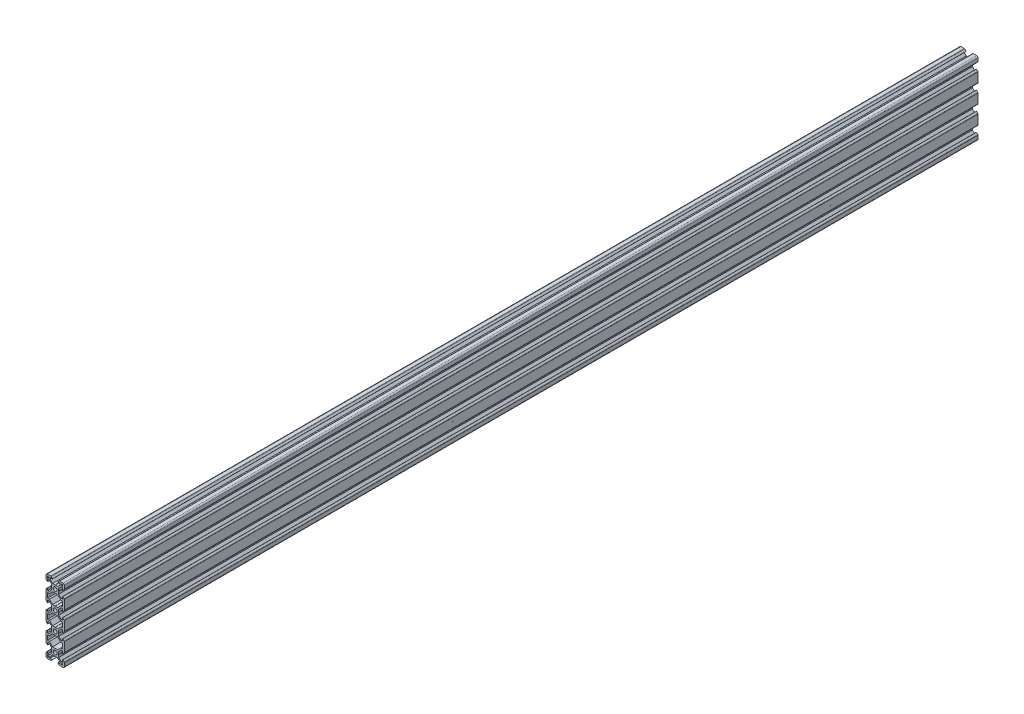
from build123d import *

# Parameters (mm, degrees)
SKETCH3_R           = 2.1
BOSS_EXTRUDE1_DEPTH = 1000


with BuildPart() as part:
    # Sketch3 → Boss-Extrude1 (new body)
    with BuildSketch(Plane.XY):
        with BuildLine():
            Line((-0.1, 3.9), (0, 3.8))
            Line((0, 3.8), (0.1, 3.9))
            Line((0.1, 3.9), (2.840365134, 3.9))
            Line((2.840365134, 3.9), (5.5, 6.558825842))
            Line((5.5, 6.558825842), (5.5, 8.197505675))
            Line((5.5, 8.197505675), (2.89, 8.197505675))
            Line((2.89, 8.197505675), (2.89, 8.307505675))
            Line((2.89, 8.307505675), (4.348614357, 9.766120032))
            ThreePointArc((4.348614357, 9.766120032), (4.604908803, 9.937370505), (4.907228714, 9.997505675))
            Line((4.907228714, 9.997505675), (8.5, 9.997505675))
            ThreePointArc((8.5, 9.997505675), (9.560660172, 9.558165846), (10, 8.497505675))
            Line((10, 8.497505675), (10, 4.904734389))
            ThreePointArc((10, 4.904734389), (9.939864831, 4.602414477), (9.768614357, 4.346120032))
            Line((9.768614357, 4.346120032), (8.31, 2.887505675))
            Line((8.31, 2.887505675), (8.2, 2.887505675))
            Line((8.2, 2.887505675), (8.2, 5.497505675))
            Line((8.2, 5.497505675), (6.56, 5.497505675))
            Line((6.56, 5.497505675), (3.9, 2.83831481))
            Line((3.9, 2.83831481), (3.9, 0.1))
            Line((3.9, 0.1), (3.8, 0))
            Line((3.8, 0), (3.9, -0.1))
            Line((3.9, -0.1), (3.9, -2.84))
            Line((3.9, -2.84), (6.56, -5.5))
            Line((6.56, -5.5), (8.21, -5.5))
            Line((8.21, -5.5), (8.21, -2.89))
            Line((8.21, -2.89), (8.31, -2.89))
            Line((8.31, -2.89), (9.765685425, -4.345685425))
            ThreePointArc((9.765685425, -4.345685425), (9.939103626, -4.605224104), (10, -4.91137085))
            Line((10, -4.91137085), (10, -15.08862915))
            ThreePointArc((10, -15.08862915), (9.939103626, -15.394775896), (9.765685425, -15.654314575))
            Line((9.765685425, -15.654314575), (8.31, -17.11))
            Line((8.31, -17.11), (8.21, -17.11))
            Line((8.21, -17.11), (8.21, -14.5))
            Line((8.21, -14.5), (6.56, -14.5))
            Line((6.56, -14.5), (3.9, -17.16))
            Line((3.9, -17.16), (3.9, -19.9))
            Line((3.9, -19.9), (3.8, -20))
            Line((3.8, -20), (3.9, -20.1))
            Line((3.9, -20.1), (3.9, -22.838679656))
            Line((3.9, -22.838679656), (6.56, -25.498679656))
            Line((6.56, -25.498679656), (8.21, -25.498679656))
            Line((8.21, -25.498679656), (8.21, -22.888679656))
            Line((8.21, -22.888679656), (8.31, -22.888679656))
            Line((8.31, -22.888679656), (9.765685425, -24.344365081))
            ThreePointArc((9.765685425, -24.344365081), (9.939103626, -24.60390376), (10, -24.910050506))
            Line((10, -24.910050506), (10, -35.109949494))
            ThreePointArc((10, -35.109949494), (9.939103626, -35.41609624), (9.765685425, -35.675634919))
            Line((9.765685425, -35.675634919), (8.31, -37.131320344))
            Line((8.31, -37.131320344), (8.21, -37.131320344))
            Line((8.21, -37.131320344), (8.21, -34.521320344))
            Line((8.21, -34.521320344), (6.56, -34.521320344))
            Line((6.56, -34.521320344), (3.9, -37.181320344))
            Line((3.9, -37.181320344), (3.9, -39.92))
            Line((3.9, -39.92), (3.8, -40.02))
            Line((3.8, -40.02), (3.9, -40.12))
            Line((3.9, -40.12), (3.9, -42.86))
            Line((3.9, -42.86), (6.56, -45.52))
            Line((6.56, -45.52), (8.21, -45.52))
            Line((8.21, -45.52), (8.21, -42.91))
            Line((8.21, -42.91), (8.31, -42.91))
            Line((8.31, -42.91), (9.765685425, -44.365685425))
            ThreePointArc((9.765685425, -44.365685425), (9.939103626, -44.625224104), (10, -44.93137085))
            Line((10, -44.93137085), (10, -55.10862915))
            ThreePointArc((10, -55.10862915), (9.939103626, -55.414775896), (9.765685425, -55.674314575))
            Line((9.765685425, -55.674314575), (8.31, -57.13))
            Line((8.31, -57.13), (8.21, -57.13))
            Line((8.21, -57.13), (8.21, -54.52))
            Line((8.21, -54.52), (6.56, -54.52))
            Line((6.56, -54.52), (3.9, -57.18))
            Line((3.9, -57.18), (3.9, -59.92))
            Line((3.9, -59.92), (3.8, -60.02))
            Line((3.8, -60.02), (3.9, -60.12))
            Line((3.9, -60.12), (3.9, -62.85831481))
            Line((3.9, -62.85831481), (6.56, -65.517505675))
            Line((6.56, -65.517505675), (8.2, -65.517505675))
            Line((8.2, -65.517505675), (8.2, -62.907505675))
            Line((8.2, -62.907505675), (8.31, -62.907505675))
            Line((8.31, -62.907505675), (9.768614357, -64.366120032))
            ThreePointArc((9.768614357, -64.366120032), (9.939864831, -64.622414477), (10, -64.924734389))
            Line((10, -64.924734389), (10, -68.517505675))
            ThreePointArc((10, -68.517505675), (9.560660172, -69.578165846), (8.5, -70.017505675))
            Line((8.5, -70.017505675), (4.907228714, -70.017505675))
            ThreePointArc((4.907228714, -70.017505675), (4.604908803, -69.957370505), (4.348614357, -69.786120032))
            Line((4.348614357, -69.786120032), (2.89, -68.327505675))
            Line((2.89, -68.327505675), (2.89, -68.217505675))
            Line((2.89, -68.217505675), (5.5, -68.217505675))
            Line((5.5, -68.217505675), (5.5, -66.578825842))
            Line((5.5, -66.578825842), (2.840365134, -63.92))
            Line((2.840365134, -63.92), (0.1, -63.92))
            Line((0.1, -63.92), (0, -63.82))
            Line((0, -63.82), (-0.1, -63.92))
            Line((-0.1, -63.92), (-2.840365134, -63.92))
            Line((-2.840365134, -63.92), (-5.5, -66.578825842))
            Line((-5.5, -66.578825842), (-5.5, -68.217505675))
            Line((-5.5, -68.217505675), (-2.89, -68.217505675))
            Line((-2.89, -68.217505675), (-2.89, -68.327505675))
            Line((-2.89, -68.327505675), (-4.348614357, -69.786120032))
            ThreePointArc((-4.348614357, -69.786120032), (-4.604908803, -69.957370505), (-4.907228714, -70.017505675))
            Line((-4.907228714, -70.017505675), (-8.5, -70.017505675))
            ThreePointArc((-8.5, -70.017505675), (-9.560660172, -69.578165846), (-10, -68.517505675))
            Line((-10, -68.517505675), (-10, -64.924734389))
            ThreePointArc((-10, -64.924734389), (-9.939864831, -64.622414477), (-9.768614357, -64.366120032))
            Line((-9.768614357, -64.366120032), (-8.31, -62.907505675))
            Line((-8.31, -62.907505675), (-8.2, -62.907505675))
            Line((-8.2, -62.907505675), (-8.2, -65.517505675))
            Line((-8.2, -65.517505675), (-6.56, -65.517505675))
            Line((-6.56, -65.517505675), (-3.9, -62.85831481))
            Line((-3.9, -62.85831481), (-3.9, -60.12))
            Line((-3.9, -60.12), (-3.8, -60.02))
            Line((-3.8, -60.02), (-3.9, -59.92))
            Line((-3.9, -59.92), (-3.9, -57.18))
            Line((-3.9, -57.18), (-6.56, -54.52))
            Line((-6.56, -54.52), (-8.21, -54.52))
            Line((-8.21, -54.52), (-8.21, -57.13))
            Line((-8.21, -57.13), (-8.31, -57.13))
            Line((-8.31, -57.13), (-9.765685425, -55.674314575))
            ThreePointArc((-9.765685425, -55.674314575), (-9.939103626, -55.414775896), (-10, -55.10862915))
            Line((-10, -55.10862915), (-10, -44.93137085))
            ThreePointArc((-10, -44.93137085), (-9.939103626, -44.625224104), (-9.765685425, -44.365685425))
            Line((-9.765685425, -44.365685425), (-8.31, -42.91))
            Line((-8.31, -42.91), (-8.21, -42.91))
            Line((-8.21, -42.91), (-8.21, -45.52))
            Line((-8.21, -45.52), (-6.56, -45.52))
            Line((-6.56, -45.52), (-3.9, -42.86))
            Line((-3.9, -42.86), (-3.9, -40.12))
            Line((-3.9, -40.12), (-3.8, -40.02))
            Line((-3.8, -40.02), (-3.9, -39.92))
            Line((-3.9, -39.92), (-3.9, -37.181320344))
            Line((-3.9, -37.181320344), (-6.56, -34.521320344))
            Line((-6.56, -34.521320344), (-8.21, -34.521320344))
            Line((-8.21, -34.521320344), (-8.21, -37.131320344))
            Line((-8.21, -37.131320344), (-8.31, -37.131320344))
            Line((-8.31, -37.131320344), (-9.765685425, -35.675634919))
            ThreePointArc((-9.765685425, -35.675634919), (-9.939103626, -35.41609624), (-10, -35.109949494))
            Line((-10, -35.109949494), (-10, -24.910050506))
            ThreePointArc((-10, -24.910050506), (-9.939103626, -24.60390376), (-9.765685425, -24.344365081))
            Line((-9.765685425, -24.344365081), (-8.31, -22.888679656))
            Line((-8.31, -22.888679656), (-8.21, -22.888679656))
            Line((-8.21, -22.888679656), (-8.21, -25.498679656))
            Line((-8.21, -25.498679656), (-6.56, -25.498679656))
            Line((-6.56, -25.498679656), (-3.9, -22.838679656))
            Line((-3.9, -22.838679656), (-3.9, -20.1))
            Line((-3.9, -20.1), (-3.8, -20))
            Line((-3.8, -20), (-3.9, -19.9))
            Line((-3.9, -19.9), (-3.9, -17.16))
            Line((-3.9, -17.16), (-6.56, -14.5))
            Line((-6.56, -14.5), (-8.21, -14.5))
            Line((-8.21, -14.5), (-8.21, -17.11))
            Line((-8.21, -17.11), (-8.31, -17.11))
            Line((-8.31, -17.11), (-9.765685425, -15.654314575))
            ThreePointArc((-9.765685425, -15.654314575), (-9.939103626, -15.394775896), (-10, -15.08862915))
            Line((-10, -15.08862915), (-10, -4.91137085))
            ThreePointArc((-10, -4.91137085), (-9.939103626, -4.605224104), (-9.765685425, -4.345685425))
            Line((-9.765685425, -4.345685425), (-8.31, -2.89))
            Line((-8.31, -2.89), (-8.21, -2.89))
            Line((-8.21, -2.89), (-8.21, -5.5))
            Line((-8.21, -5.5), (-6.56, -5.5))
            Line((-6.56, -5.5), (-3.9, -2.84))
            Line((-3.9, -2.84), (-3.9, -0.1))
            Line((-3.9, -0.1), (-3.8, 0))
            Line((-3.8, 0), (-3.9, 0.1))
            Line((-3.9, 0.1), (-3.9, 2.83831481))
            Line((-3.9, 2.83831481), (-6.56, 5.497505675))
            Line((-6.56, 5.497505675), (-8.2, 5.497505675))
            Line((-8.2, 5.497505675), (-8.2, 2.887505675))
            Line((-8.2, 2.887505675), (-8.31, 2.887505675))
            Line((-8.31, 2.887505675), (-9.768614357, 4.346120032))
            ThreePointArc((-9.768614357, 4.346120032), (-9.939864831, 4.602414477), (-10, 4.904734389))
            Line((-10, 4.904734389), (-10, 8.497505675))
            ThreePointArc((-10, 8.497505675), (-9.560660172, 9.558165846), (-8.5, 9.997505675))
            Line((-8.5, 9.997505675), (-4.907228714, 9.997505675))
            ThreePointArc((-4.907228714, 9.997505675), (-4.604908803, 9.937370505), (-4.348614357, 9.766120032))
            Line((-4.348614357, 9.766120032), (-2.89, 8.307505675))
            Line((-2.89, 8.307505675), (-2.89, 8.197505675))
            Line((-2.89, 8.197505675), (-5.5, 8.197505675))
            Line((-5.5, 8.197505675), (-5.5, 6.558825842))
            Line((-5.5, 6.558825842), (-2.840365134, 3.9))
            Line((-2.840365134, 3.9), (-0.1, 3.9))
        make_face()
        Circle(SKETCH3_R, mode=Mode.SUBTRACT)
        with Locations((0, -20)):
            Circle(SKETCH3_R, mode=Mode.SUBTRACT)
        with Locations((0, -40.02)):
            Circle(SKETCH3_R, mode=Mode.SUBTRACT)
        with Locations((0, -60.02)):
            Circle(SKETCH3_R, mode=Mode.SUBTRACT)
        Polygon((-7.66, 6.567505675), (-6.57, 7.657505675), (-6.57, 8.197505675), (-8.2, 8.197505675), (-8.2, 6.567505675), align=None, mode=Mode.SUBTRACT)
        Polygon((2.840365134, -3.9), (-2.840365134, -3.9), (-6.25, -7.309634866), (-8.21, -7.309634866), (-8.21, -12.7), (-6.25, -12.7), (-2.85, -16.1), (-0.1, -16.1), (0, -16.2), (0.1, -16.1), (2.85, -16.1), (6.25, -12.7), (8.21, -12.7), (8.21, -7.309634866), (6.25, -7.309634866), align=None, mode=Mode.SUBTRACT)
        Polygon((-0.1, -23.9), (0, -23.8), (0.1, -23.9), (2.84, -23.9), (6.25, -27.31), (8.21, -27.31), (8.21, -32.71), (6.25, -32.71), (2.84, -36.12), (0.1, -36.12), (0, -36.22), (-0.1, -36.12), (-2.84, -36.12), (-6.25, -32.71), (-8.21, -32.71), (-8.21, -27.31), (-6.25, -27.31), (-2.84, -23.9), align=None, mode=Mode.SUBTRACT)
        Polygon((8.2, 6.567505675), (7.66, 6.567505675), (6.57, 7.657505675), (6.57, 8.197505675), (8.2, 8.197505675), align=None, mode=Mode.SUBTRACT)
        Polygon((7.66, -66.587505675), (6.57, -67.677505675), (6.57, -68.217505675), (8.2, -68.217505675), (8.2, -66.587505675), align=None, mode=Mode.SUBTRACT)
        Polygon((2.840365134, -56.12), (6.25, -52.710365134), (8.21, -52.710365134), (8.21, -47.32), (6.25, -47.32), (2.85, -43.92), (0.1, -43.92), (0, -43.82), (-0.1, -43.92), (-2.85, -43.92), (-6.25, -47.32), (-8.21, -47.32), (-8.21, -52.710365134), (-6.25, -52.710365134), (-2.840365134, -56.12), align=None, mode=Mode.SUBTRACT)
        Polygon((-8.2, -66.587505675), (-7.66, -66.587505675), (-6.57, -67.677505675), (-6.57, -68.217505675), (-8.2, -68.217505675), align=None, mode=Mode.SUBTRACT)
    extrude(amount=-BOSS_EXTRUDE1_DEPTH)


solid = part.part
